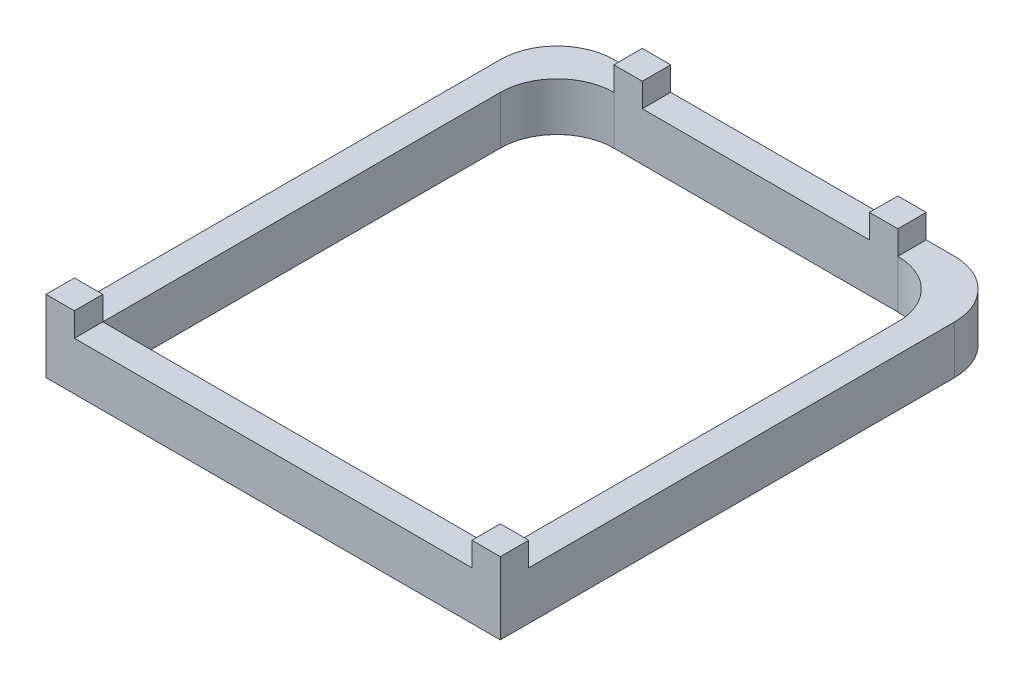
from build123d import *

# Parameters (mm, degrees)
BOSS_EXTRUDE1_DEPTH = 1.7
BOSS_EXTRUDE3_DEPTH = 1.7
CUT_EXTRUDE1_DEPTH  = 1.7
SKETCH5_W           = 1
SKETCH5_H           = 1
BOSS_EXTRUDE4_DEPTH = 0.84


with BuildPart() as part:
    # Sketch1 → Boss-Extrude1 (new body)
    with BuildSketch(Plane(origin=(0, 0, 0), x_dir=(1, 0, 0), z_dir=(0, 1, 0))):
        with BuildLine():
            Line((-5, 8), (5, 8))
            ThreePointArc((5, 8), (6.414213562, 7.414213562), (7, 6))
            Line((7, 6), (7, -8))
            Line((7, -8), (-7, -8))
            Line((-7, -8), (-7, 6))
            ThreePointArc((-7, 6), (-6.414213562, 7.414213562), (-5, 8))
        make_face()
    extrude(amount=BOSS_EXTRUDE1_DEPTH)

    # Sketch3 → Boss-Extrude3 (add)
    with BuildSketch(Plane(origin=(0, 0, 0), x_dir=(1, 0, 0), z_dir=(0, 1, 0))):
        with BuildLine():
            Line((-6, 9), (6, 9))
            ThreePointArc((6, 9), (7.414213562, 8.414213562), (8, 7))
            Line((8, 7), (8, -9))
            Line((8, -9), (-8, -9))
            Line((-8, -9), (-8, 7))
            ThreePointArc((-8, 7), (-7.414213562, 8.414213562), (-6, 9))
        make_face()
    extrude(amount=BOSS_EXTRUDE3_DEPTH)

    # Sketch1_2 → Cut-Extrude1 (cut)
    with BuildSketch(Plane(origin=(0, 0, 0), x_dir=(1, 0, 0), z_dir=(0, 1, 0))):
        with BuildLine():
            Line((-5, 8), (5, 8))
            ThreePointArc((5, 8), (6.414213562, 7.414213562), (7, 6))
            Line((7, 6), (7, -8))
            Line((7, -8), (-7, -8))
            Line((-7, -8), (-7, 6))
            ThreePointArc((-7, 6), (-6.414213562, 7.414213562), (-5, 8))
        make_face()
    extrude(amount=CUT_EXTRUDE1_DEPTH, mode=Mode.SUBTRACT)

    # Sketch5 → Boss-Extrude4 (add)
    with BuildSketch(Plane(origin=(0, 1.7, 0), x_dir=(1, 0, 0), z_dir=(0, 1, 0))):
        with Locations((-4.5, 8.5)):
            Rectangle(SKETCH5_W, SKETCH5_H)
        with Locations((-7.5, -8.5)):
            Rectangle(SKETCH5_W, SKETCH5_H)
        with Locations((7.5, -8.5)):
            Rectangle(SKETCH5_W, SKETCH5_H)
        with Locations((4.5, 8.5)):
            Rectangle(SKETCH5_W, SKETCH5_H)
    extrude(amount=BOSS_EXTRUDE4_DEPTH)


solid = part.part
